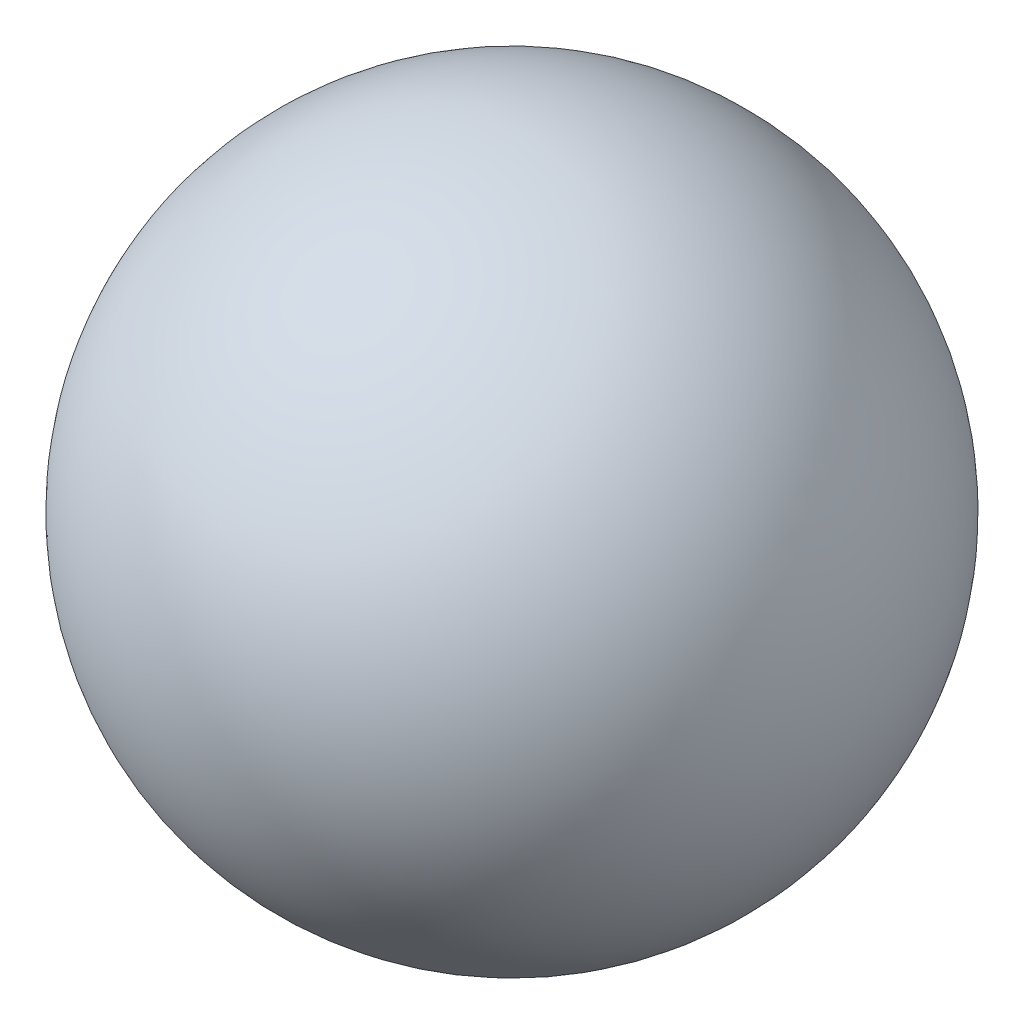
from build123d import *


with BuildPart() as part:
    # Sketch1 → Revolve3 (revolve)
    with BuildSketch(Plane.XY):
        with BuildLine():
            Line((-15, 0), (15, 0))
            ThreePointArc((15, 0), (0, 15), (-15, 0))
        make_face()
    revolve(axis=Axis((-30.51746377, 0, 0), (1, 0, 0)))


solid = part.part
